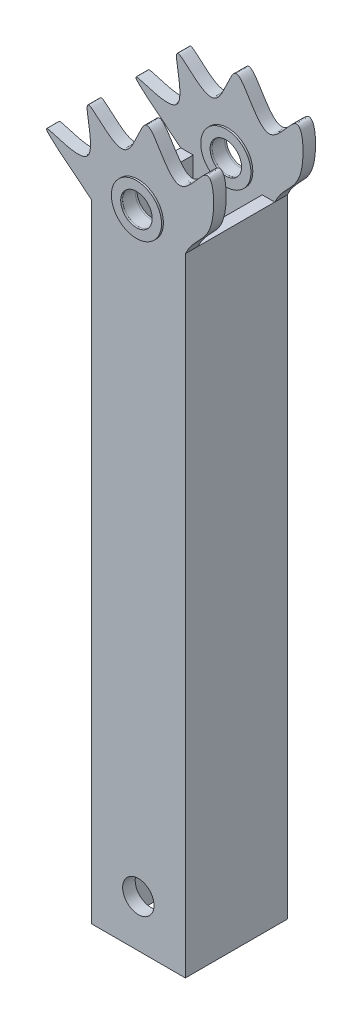
from build123d import *

# Parameters (mm, degrees)
SKETCH1_W            = 38.1
SKETCH1_H            = 254
BOSS_EXTRUDE1_DEPTH  = 20.6375
SKETCH2_W            = 27.94
SKETCH2_H            = 15.5575
CUT_EXTRUDE1_DEPTH   = 255
BOSS_EXTRUDE2_DEPTH  = 5.08
SKETCH4_R            = 6.35
CUT_EXTRUDE2_DEPTH   = 21.6375
SKETCH7_R            = 10.16
SKETCH7_R_2          = 6.3754
BOSS_EXTRUDE7_DEPTH  = 0.762
SKETCH5_R            = 10.16
SKETCH5_R_2          = 6.3754
BOSS_EXTRUDE8_DEPTH  = 0.762
SKETCH8_R            = 10.16
SKETCH8_R_2          = 6.3754
BOSS_EXTRUDE9_DEPTH  = 0.762
SKETCH6_R            = 10.16
SKETCH6_R_2          = 6.3754
BOSS_EXTRUDE10_DEPTH = 0.762


with BuildPart() as part:
    # Sketch1 → Boss-Extrude1 (new body)
    with BuildSketch(Plane.XY):
        Rectangle(SKETCH1_W, SKETCH1_H)
    boss_extrude1 = extrude(amount=-BOSS_EXTRUDE1_DEPTH)

    # Sketch2 → Cut-Extrude1 (cut, through all)
    with BuildSketch(Plane(origin=(0, 127, 0), x_dir=(1, 0, 0), z_dir=(0, 1, 0))):
        with Locations((0, 12.85875)):
            Rectangle(SKETCH2_W, SKETCH2_H)
    cut_extrude1 = extrude(amount=-CUT_EXTRUDE1_DEPTH, mode=Mode.SUBTRACT)

    # Sketch3 → Boss-Extrude2 (add)
    with BuildSketch(Plane.XY):
        with BuildLine():
            Line((19.05, -127), (19.05, 127))
            add(Edge.make_bspline(
                [(-19.05, 127), (-56.075315262, 156.249850392), (-8.765115366, 122.455949853), (-26.712109458, 171.110128284), (-3.384581259, 140.1026882), (2.775851656, 177.747781306), (14.812642132, 138.429098192), (30.466954619, 168.517170498), (31.839042912, 136.04797914), (22.264682919, 133.908235623), (19.05, 127)],
                knots=[0, 0, 0, 0, 0.207464244, 0.325922959, 0.435664574, 0.542830686, 0.674868849, 0.767184926, 0.882236084, 1, 1, 1, 1], degree=3))
            Line((-19.05, 127), (-19.05, -127))
            Line((-19.05, -127), (19.05, -127))
        make_face()
    boss_extrude2 = extrude(amount=-BOSS_EXTRUDE2_DEPTH)

    # Sketch4 → Cut-Extrude2 (cut, through all)
    with BuildSketch(Plane.XY):
        with Locations((0, 133.35)):
            Circle(SKETCH4_R)
        with Locations((0, -107.95)):
            Circle(SKETCH4_R)
    cut_extrude2 = extrude(amount=-CUT_EXTRUDE2_DEPTH, mode=Mode.SUBTRACT)

    # Mirror1: Boss-Extrude1, Cut-Extrude1, Boss-Extrude2, Cut-Extrude2 across plane
    add(boss_extrude1.mirror(Plane.XY.offset(-20.6375)))
    add(cut_extrude1.mirror(Plane.XY.offset(-20.6375)), mode=Mode.SUBTRACT)
    add(boss_extrude2.mirror(Plane.XY.offset(-20.6375)))
    add(cut_extrude2.mirror(Plane.XY.offset(-20.6375)), mode=Mode.SUBTRACT)

    # Sketch7 → Boss-Extrude7 (add)
    with BuildSketch(Plane(origin=(0, 0, -5.08), x_dir=(-1, 0, 0), z_dir=(0, 0, -1))):
        with Locations((0, 133.35)):
            Circle(SKETCH7_R)
        with Locations((0, 133.35)):
            Circle(SKETCH7_R_2, mode=Mode.SUBTRACT)
    extrude(amount=BOSS_EXTRUDE7_DEPTH)

    # Sketch5 → Boss-Extrude8 (add)
    with BuildSketch(Plane.XY):
        with Locations((0, 133.35)):
            Circle(SKETCH5_R)
        with Locations((0, 133.35)):
            Circle(SKETCH5_R_2, mode=Mode.SUBTRACT)
    extrude(amount=BOSS_EXTRUDE8_DEPTH)

    # Sketch8 → Boss-Extrude9 (add)
    with BuildSketch(Plane.XY.offset(-36.195)):
        with Locations((0, 133.35)):
            Circle(SKETCH8_R)
        with Locations((0, 133.35)):
            Circle(SKETCH8_R_2, mode=Mode.SUBTRACT)
    extrude(amount=BOSS_EXTRUDE9_DEPTH)

    # Sketch6 → Boss-Extrude10 (add)
    with BuildSketch(Plane(origin=(0, 0, -41.275), x_dir=(-1, 0, 0), z_dir=(0, 0, -1))):
        with Locations((0, 133.35)):
            Circle(SKETCH6_R)
        with Locations((0, 133.35)):
            Circle(SKETCH6_R_2, mode=Mode.SUBTRACT)
    extrude(amount=BOSS_EXTRUDE10_DEPTH)


solid = part.part
